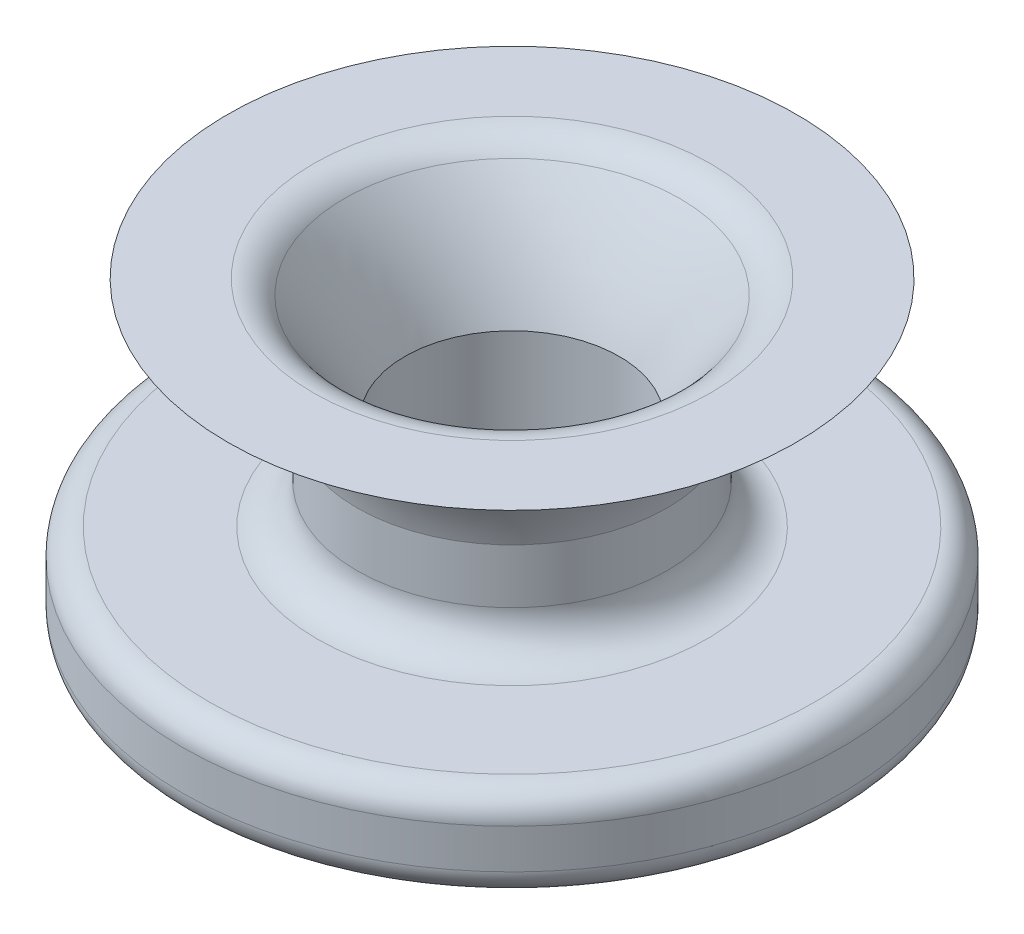
from build123d import *

# Parameters (mm, degrees)
SKETCH1_R               = 63.5
BOSS_EXTRUDE1_DEPTH     = 17.78
SKETCH4_R               = 25.36657104
BOSS_EXTRUDE6_DEPTH     = 20.32
SKETCH6_R               = 19.05
CUT_EXTRUDE1_DEPTH      = 20.32
SKETCH12_R              = 3.81
CUT_EXTRUDE6_DEPTH      = 39.13342896
CUT_EXTRUDE6_DEPTH_BACK = 89.86657104
FILLET2_R               = 5.08
FILLET4_R               = 2.54
FILLET5_R               = 5.08
FILLET6_R               = 7.62
FILLET7_R               = 7.62


with BuildPart() as part:
    # Sketch1 → Boss-Extrude1 (new body)
    with BuildSketch(Plane(origin=(0, 0, 0), x_dir=(1, 0, 0), z_dir=(0, 1, 0))):
        Circle(SKETCH1_R)
    extrude(amount=BOSS_EXTRUDE1_DEPTH)

    # Sketch4 → Boss-Extrude6 (add)
    with BuildSketch(Plane.XZ):
        Circle(SKETCH4_R)
    extrude(amount=BOSS_EXTRUDE6_DEPTH)

    # Sketch6 → Cut-Extrude1 (cut)
    with BuildSketch(Plane.XZ.offset(20.32)):
        Circle(SKETCH6_R)
    extrude(amount=-CUT_EXTRUDE1_DEPTH, mode=Mode.SUBTRACT)

    # Sketch12 → Cut-Extrude6 (cut, two sides)
    with BuildSketch(Plane(origin=(0, 0, -25.36657104), x_dir=(-1, 0, 0), z_dir=(0, 0, -1))) as cut_extrude6_sk:
        with Locations((0, -10.248937759)):
            Circle(SKETCH12_R)
    extrude(amount=CUT_EXTRUDE6_DEPTH, mode=Mode.SUBTRACT)
    extrude(cut_extrude6_sk.sketch, amount=-CUT_EXTRUDE6_DEPTH_BACK, mode=Mode.SUBTRACT)

    # Fillet2
    fillet2_edges = [part.edges().sort_by_distance(p)[0] for p in [
        (-63.5, 0, 0),
        (-25.36657104, 0, 0),
    ]]
    fillet(fillet2_edges, radius=FILLET2_R)

    # Fillet4
    fillet4_edges = [part.edges().sort_by_distance(p)[0] for p in [
        (-19.05, -20.32, 0),
    ]]
    fillet(fillet4_edges, radius=FILLET4_R)

    # Fillet5
    fillet5_edges = [part.edges().sort_by_distance(p)[0] for p in [
        (-63.5, 17.78, 0),
    ]]
    fillet(fillet5_edges, radius=FILLET5_R)

    # Sketch15 → Revolve2 (revolve)
    with BuildSketch(Plane.XY):
        with BuildLine():
            Line((-29.892018592, 17.78), (-29.892018592, 35.864083574))
            add(Edge.make_bspline(
                [(-29.892018592, 35.864083574), (-34.469720998, 58.177644888), (-54.765059219, 59.2336397)],
                knots=[0, 0, 0, 1, 1, 1], degree=2))
            Line((-54.765059219, 59.2336397), (0, 59.2336397))
            Line((0, 59.2336397), (0, 17.78))
            Line((0, 17.78), (-29.892018592, 17.78))
        make_face()
    revolve(axis=Axis((0, 59.2336397, 0), (0, -1, 0)))

    # Sketch17 → Cut-Revolve2 (revolve, cut)
    with BuildSketch(Plane.XY):
        with BuildLine():
            Line((-20.673805288, 17.789082093), (-20.673805288, 35.864083574))
            add(Edge.make_bspline(
                [(-20.673805288, 35.864083574), (-26.033336051, 50.170850095), (-36.460310019, 61.106483535)],
                knots=[0, 0, 0, 1, 1, 1], degree=2))
            Line((-36.460310019, 61.106483535), (0, 61.106483535))
            Line((0, 61.106483535), (0, 17.789082093))
            Line((0, 17.789082093), (-20.673805288, 17.789082093))
        make_face()
    revolve(axis=Axis((0, 61.106483535, 0), (0, -1, 0)), mode=Mode.SUBTRACT)

    # Fillet6
    fillet6_edges = [part.edges().sort_by_distance(p)[0] for p in [
        (29.892018592, 17.78, 0),
    ]]
    fillet(fillet6_edges, radius=FILLET6_R)

    # Fillet7
    fillet7_edges = [part.edges().sort_by_distance(p)[0] for p in [
        (34.733754096, 59.2336397, 6e-09),
    ]]
    fillet(fillet7_edges, radius=FILLET7_R)


solid = part.part
